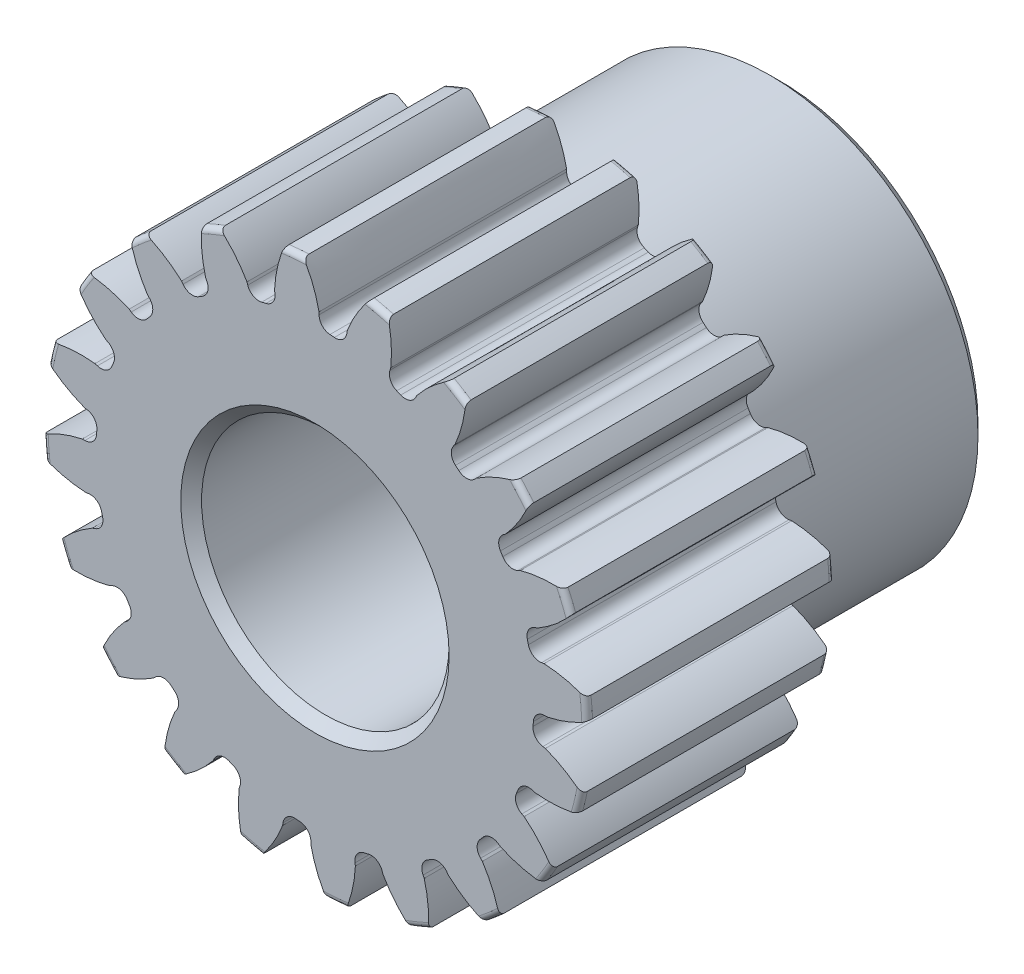
from build123d import *

# Parameters (mm, degrees)
SKETCH1_R                = 13.97
BOSS_EXTRUDE1_DEPTH      = 12.7
SKETCH2_W                = 11.176
SKETCH2_H                = 10.668
FILLET2_R                = 0.2794
CUT_EXTRUDE1_DEPTH       = 24.876
FILLET1_R                = 0.5984748
CIRPATTERN1_COUNT        = 20
FILLET1_OF_CIRPATTERN1_R = 0.5984748
SKETCH5_R                = 6.35
CUT_EXTRUDE2_DEPTH       = 24.876
CHAMFER1_SIZE            = 0.5334


with BuildPart() as part:
    # Sketch1 → Boss-Extrude1 (new body)
    with BuildSketch(Plane.XY):
        Circle(SKETCH1_R)
    extrude(amount=-BOSS_EXTRUDE1_DEPTH)

    # Sketch2 → Revolve1 (revolve)
    with BuildSketch(Plane(origin=(0, 0, 0), x_dir=(0, 0, -1), z_dir=(1, 0, 0))):
        with Locations((18.288, 5.334)):
            Rectangle(SKETCH2_W, SKETCH2_H)
    revolve(axis=Axis((0, 0, -12.7), (0, 0, -1)))

    # Fillet2
    fillet2_edges = [part.edges().sort_by_distance(p)[0] for p in [
        (-13.97, 0, 0),
        (-13.97, 0, -12.7),
        (0, -10.668, -12.7),
    ]]
    fillet(fillet2_edges, radius=FILLET2_R)

    # Sketch4 → Cut-Extrude1 (cut, through all)
    with BuildSketch(Plane.XY):
        with BuildLine():
            Line((0.210823499, 11.932233972), (0.210823499, 11.228631013))
            ThreePointArc((0.210823499, 11.228631013), (0.881145561, 11.195989616), (1.54832106, 11.123367425))
            Line((1.54832106, 11.123367425), (1.658389068, 11.818307824))
            add(Edge.make_bspline(
                [(5.904499611, 15.819097373), (2.715567633, 14.578951978), (1.658389068, 11.818307824)],
                knots=[0, 0, 0, 1, 1, 1], degree=2))
            ThreePointArc((5.904499611, 15.819097373), (1.324793594, 16.833059119), (-3.35714731, 16.548006506))
            add(Edge.make_bspline(
                [(-3.35714731, 16.548006506), (-0.40147849, 14.824269404), (0.210823499, 11.932233972)],
                knots=[0, 0, 0, 1, 1, 1], degree=2))
        make_face()
    cut_extrude1 = extrude(amount=-CUT_EXTRUDE1_DEPTH, mode=Mode.SUBTRACT)

    # Fillet1
    fillet1_edges = [part.edges().sort_by_distance(p)[0] for p in [
        (1.54832106, 11.123367425, -6.35),
        (0.210823499, 11.228631013, -6.35),
    ]]
    fillet(fillet1_edges, radius=FILLET1_R)

    # CirPattern1: Cut-Extrude1 ×20 about axis
    cirpattern1_axis = Axis((0, 0, -12.7), (0, 0, 1))
    for i in range(1, CIRPATTERN1_COUNT):
        add(cut_extrude1.rotate(cirpattern1_axis, i * 360 / CIRPATTERN1_COUNT), mode=Mode.SUBTRACT)

    # Fillet1 of CirPattern1
    fillet1_of_cirpattern1_edges = [part.edges().sort_by_distance(p)[0] for p in [
        (-1.964768736, 11.057408593, -6.35),
        (-3.269332744, 10.744210738, -6.35),
        (-5.285533278, 9.909073566, -6.35),
        (-6.429463919, 9.208072256, -6.35),
        (-8.088912997, 7.790769378, -6.35),
        (-8.96023437, 6.770583506, -6.35),
        (-10.100493552, 4.909850402, -6.35),
        (-10.61391465, 3.670342869, -6.35),
        (-11.123367425, 1.54832106, -6.35),
        (-11.228631013, 0.210823499, -6.35),
        (-11.057408593, -1.964768736, -6.35),
        (-10.744210738, -3.269332744, -6.35),
        (-9.909073566, -5.285533278, -6.35),
        (-9.208072256, -6.429463919, -6.35),
        (-7.790769378, -8.088912997, -6.35),
        (-6.770583506, -8.96023437, -6.35),
        (-4.909850402, -10.100493552, -6.35),
        (-3.670342869, -10.61391465, -6.35),
        (-1.54832106, -11.123367425, -6.35),
        (-0.210823499, -11.228631013, -6.35),
        (1.964768736, -11.057408593, -6.35),
        (3.269332744, -10.744210738, -6.35),
        (5.285533278, -9.909073566, -6.35),
        (6.429463919, -9.208072256, -6.35),
        (8.088912997, -7.790769378, -6.35),
        (8.96023437, -6.770583506, -6.35),
        (10.100493552, -4.909850402, -6.35),
        (10.61391465, -3.670342869, -6.35),
        (11.123367425, -1.54832106, -6.35),
        (11.228631013, -0.210823499, -6.35),
        (11.057408593, 1.964768736, -6.35),
        (10.744210738, 3.269332744, -6.35),
        (9.909073566, 5.285533278, -6.35),
        (9.208072256, 6.429463919, -6.35),
        (7.790769378, 8.088912997, -6.35),
        (6.770583506, 8.96023437, -6.35),
        (4.909850402, 10.100493552, -6.35),
        (3.670342869, 10.61391465, -6.35),
    ]]
    fillet(fillet1_of_cirpattern1_edges, radius=FILLET1_OF_CIRPATTERN1_R)

    # Sketch5 → Cut-Extrude2 (cut, through all)
    with BuildSketch(Plane.XY):
        Circle(SKETCH5_R)
    extrude(amount=-CUT_EXTRUDE2_DEPTH, mode=Mode.SUBTRACT)

    # Chamfer1
    chamfer1_edges = [part.edges().sort_by_distance(p)[0] for p in [
        (0, -10.668, -23.876),
        (-6.35, 0, -23.876),
        (-6.35, 0, 0),
    ]]
    chamfer(chamfer1_edges, length=CHAMFER1_SIZE)


solid = part.part
